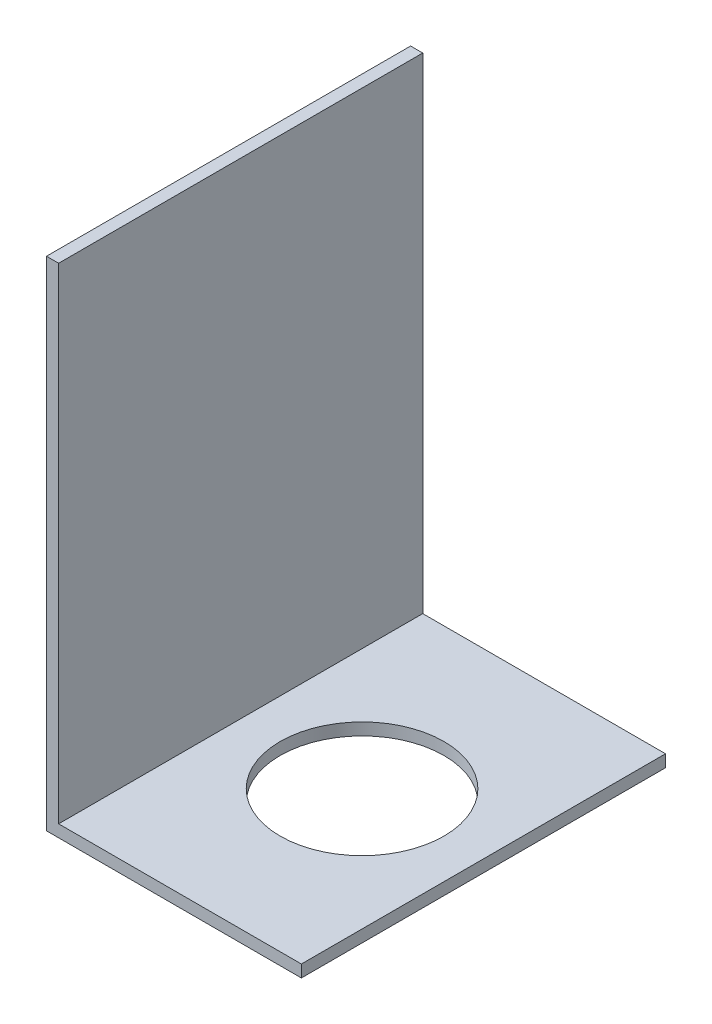
from build123d import *

# Parameters (mm, degrees)
EXTRUDE_THIN1_DEPTH       = 15
M12_CLEARANCE_SLOT1_D     = 13.5
M12_CLEARANCE_SLOT1_DEPTH = 1


with BuildPart() as part:
    # Sketch1 → Extrude-Thin1 (new body, symmetric)
    with BuildSketch(Plane.XY):
        Polygon((0, 40), (0, 0), (20, 0), (20, -1), (-1, -1), (-1, 40), align=None)
    extrude(amount=EXTRUDE_THIN1_DEPTH, both=True)

    # M12 Clearance Slot1
    with Locations(Plane(origin=(0, 0, 0), x_dir=(1, 0, 0), z_dir=(0, 1, 0))):
        with Locations((10, 0)):
            Hole(M12_CLEARANCE_SLOT1_D / 2, depth=M12_CLEARANCE_SLOT1_DEPTH)


solid = part.part
